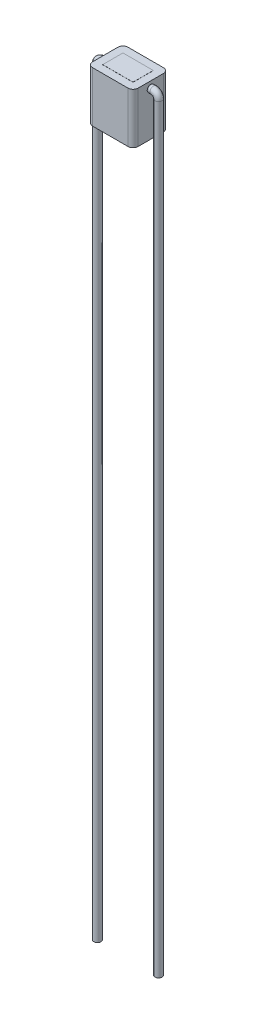
from build123d import *

# Parameters (mm, degrees)
SKETCH1_W                = 4.5
SKETCH1_H                = 3.5
BOSS_EXTRUDE1_DEPTH      = 5
SKETCH2_W                = 3
SKETCH2_H                = 2
BOSS_EXTRUDE2_DEPTH      = 5.01
BOSS_EXTRUDE2_DEPTH_BACK = 0.01
FILLET2_R                = 0.5
SKETCH14_R               = 0.35


with BuildPart() as part:
    # Sketch1 → Boss-Extrude1 (new body)
    with BuildSketch(Plane(origin=(0, 0, 0), x_dir=(1, 0, 0), z_dir=(0, 1, 0))):
        Rectangle(SKETCH1_W, SKETCH1_H)
    extrude(amount=BOSS_EXTRUDE1_DEPTH)

    # Sketch2 → Boss-Extrude2 (add, two sides)
    with BuildSketch(Plane(origin=(0, 0, 0), x_dir=(1, 0, 0), z_dir=(0, 1, 0))) as boss_extrude2_sk:
        Rectangle(SKETCH2_W, SKETCH2_H)
    extrude(amount=BOSS_EXTRUDE2_DEPTH)
    extrude(boss_extrude2_sk.sketch, amount=-BOSS_EXTRUDE2_DEPTH_BACK)

    # Fillet2
    fillet2_edges = [part.edges().sort_by_distance(p)[0] for p in [
        (2.25, 2.5, 1.75),
        (-2.25, 2.5, 1.75),
        (-2.25, 2.5, -1.75),
        (2.25, 2.5, -1.75),
    ]]
    fillet(fillet2_edges, radius=FILLET2_R)

    # Sweep1: sweep along a path in Sketch15
    with BuildLine(Plane.XY) as sweep1_path:
        Line((2.25, 4.353782078), (2.3, 4.353782078))
        Line((2.3, 4.353782078), (2.525918375, 4.353782078))
        ThreePointArc((2.525918375, 4.353782078), (2.879471766, 4.207335469), (3.025918375, 3.853782078))
        Line((3.025918375, 3.853782078), (3.025918375, -71.146217922))
    # Sketch14 → Sweep1 (sweep)
    with BuildSketch(Plane(origin=(2.25, 0, 0), x_dir=(0, 0, -1), z_dir=(1, 0, 0))):
        with Locations((0, 4.353782078)):
            Circle(SKETCH14_R)
    sweep1 = sweep(path=sweep1_path.line)

    # Mirror1: Sweep1 across plane
    add(sweep1.mirror(Plane(origin=(0, 0, 0), x_dir=(0, 0, 1), z_dir=(1, 0, 0))))


solid = part.part
